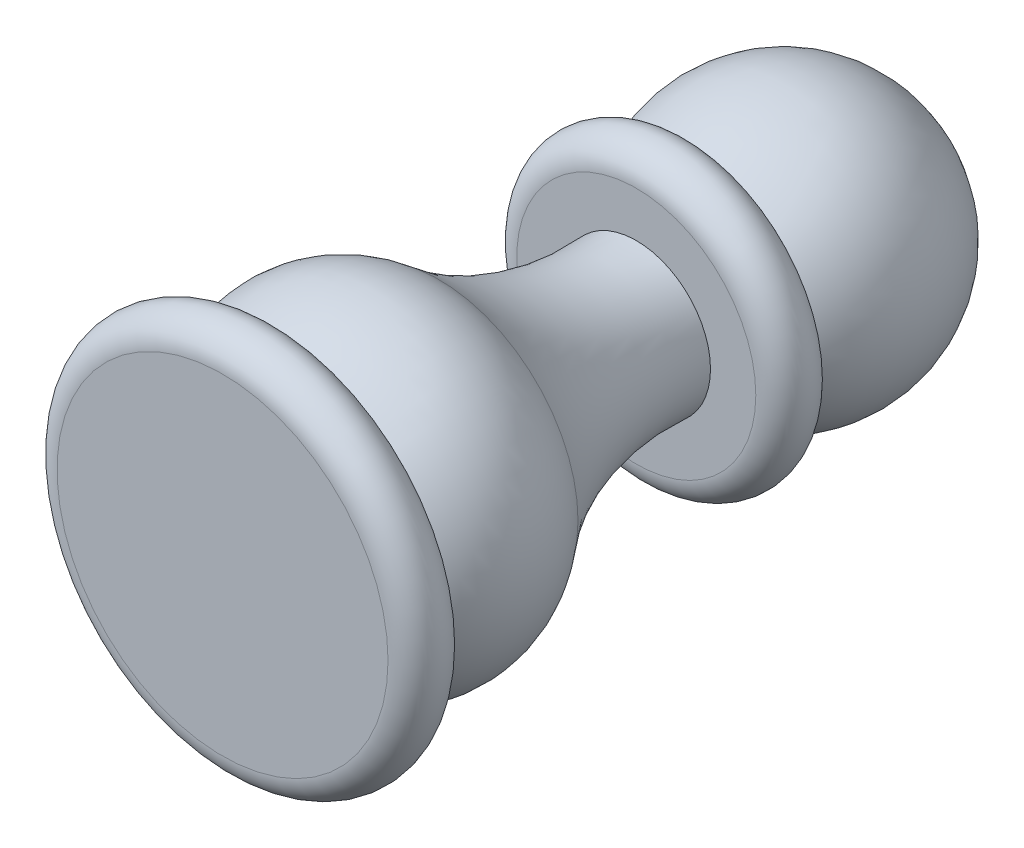
from build123d import *


with BuildPart() as part:
    # Sketch1 → Revolve1 (revolve)
    with BuildSketch(Plane(origin=(0, 0, 0), x_dir=(0, 0, -1), z_dir=(1, 0, 0))):
        with BuildLine():
            Line((3, 0), (0, 0))
            Line((0, 0), (0, -9))
            ThreePointArc((0, -9), (1.5, -10.5), (3, -9))
            Line((3, -9), (3, -6.5))
            Line((3, -6.5), (3, 0))
        make_face()
        with BuildLine():
            Line((22.5, 0), (3, 0))
            Line((3, 0), (3, -6.5))
            ThreePointArc((3, -6.5), (7.14493185, -8.955614013), (11.759531603, -7.571428571))
            ThreePointArc((11.759531603, -7.571428571), (16.783773269, -4.752416583), (22.5, -4.035070875))
            Line((22.5, -4.035070875), (22.5, 0))
        make_face()
        with BuildLine():
            Line((25.5, 0), (22.5, 0))
            Line((22.5, 0), (22.5, -4.035070875))
            Line((22.5, -4.035070875), (22.5, -6.5))
            ThreePointArc((22.5, -6.5), (24, -8), (25.5, -6.5))
            Line((25.5, -6.5), (25.5, -5.590169944))
            Line((25.5, -5.590169944), (25.5, 0))
        make_face()
        with BuildLine():
            Line((38, 0), (25.5, 0))
            Line((25.5, 0), (25.5, -5.590169944))
            ThreePointArc((25.5, -5.590169944), (33.561862178, -6.846531969), (38, 0))
        make_face()
    revolve(axis=Axis((0, 0, 0), (0, 0, -1)))


solid = part.part
